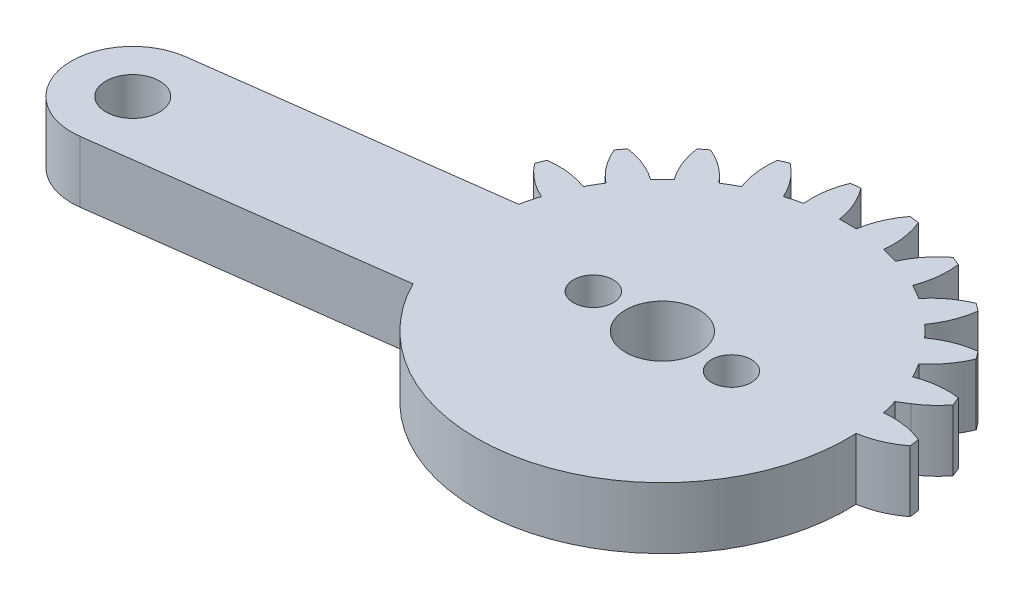
from build123d import *

# Parameters (mm, degrees)
SKETCH1_R           = 1.5
BOSS_EXTRUDE1_DEPTH = 4
SKETCH3_R           = 1.75
BOSS_EXTRUDE2_DEPTH = 4
CUT_EXTRUDE1_DEPTH  = 4
CUT_EXTRUDE2_REACH  = 6
SKETCH5_R           = 1.3
SKETCH5_R_2         = 2.4


with BuildPart() as part:
    # Sketch1 → Boss-Extrude1 (new body)
    with BuildSketch(Plane(origin=(0, 0, 0), x_dir=(1, 0, 0), z_dir=(0, 1, 0))):
        with BuildLine():
            Line((20.643657446, 4), (2.081641936, 4))
            ThreePointArc((2.081641936, 4), (2.861028333, 4.588201733), (3.521749436, 5.30713988))
            ThreePointArc((3.521749436, 5.30713988), (3.405395609, 5.596745198), (3.282888305, 5.883801663))
            ThreePointArc((3.282888305, 5.883801663), (1.93527598, 5.894040025), (0.627094961, 5.57027124))
            ThreePointArc((0.627094961, 5.57027124), (0.366286148, 6.046375), (0.084372603, 6.510293938))
            ThreePointArc((0.084372603, 6.510293938), (1.018855105, 7.48132754), (1.683794586, 8.65351323))
            ThreePointArc((1.683794586, 8.65351323), (1.496450048, 8.903135899), (1.303821399, 9.148703928))
            ThreePointArc((1.303821399, 9.148703928), (-0.000522033, 8.809805691), (-1.180330337, 8.158486898))
            ThreePointArc((-1.180330337, 8.158486898), (-1.555477026, 8.550865528), (-1.947855656, 8.926012217))
            ThreePointArc((-1.947855656, 8.926012217), (-1.296536862, 10.105820521), (-0.957638625, 11.410163953))
            ThreePointArc((-0.957638625, 11.410163953), (-1.203206655, 11.602792602), (-1.452829324, 11.79013714))
            ThreePointArc((-1.452829324, 11.79013714), (-2.625015014, 11.125197659), (-3.596048616, 10.190715157))
            ThreePointArc((-3.596048616, 10.190715157), (-4.059967554, 10.472628702), (-4.536071314, 10.733437515))
            ThreePointArc((-4.536071314, 10.733437515), (-4.212302529, 12.041618533), (-4.222540891, 13.389230859))
            ThreePointArc((-4.222540891, 13.389230859), (-4.509597355, 13.511738163), (-4.799202674, 13.62809199))
            ThreePointArc((-4.799202674, 13.62809199), (-5.759348103, 12.682425791), (-6.455432668, 11.528463019))
            ThreePointArc((-6.455432668, 11.528463019), (-6.976508546, 11.680699536), (-7.503891752, 11.809396783))
            ThreePointArc((-7.503891752, 11.809396783), (-7.529737283, 13.156800143), (-7.888414517, 14.455843809))
            ThreePointArc((-7.888414517, 14.455843809), (-8.197396993, 14.499881098), (-8.507248835, 14.537314892))
            ThreePointArc((-8.507248835, 14.537314892), (-9.18992168, 13.375367565), (-9.563620196, 12.080565177))
            ThreePointArc((-9.563620196, 12.080565177), (-10.106342554, 12.09275), (-10.649064912, 12.080565177))
            ThreePointArc((-10.649064912, 12.080565177), (-11.022763428, 13.375367565), (-11.705436272, 14.537314892))
            ThreePointArc((-11.705436272, 14.537314892), (-12.015288115, 14.499881098), (-12.324270591, 14.455843809))
            ThreePointArc((-12.324270591, 14.455843809), (-12.682947825, 13.156800143), (-12.708793355, 11.809396783))
            ThreePointArc((-12.708793355, 11.809396783), (-13.236176561, 11.680699536), (-13.757252439, 11.528463019))
            ThreePointArc((-13.757252439, 11.528463019), (-14.453337005, 12.682425791), (-15.413482434, 13.62809199))
            ThreePointArc((-15.413482434, 13.62809199), (-15.703087752, 13.511738163), (-15.990144217, 13.389230859))
            ThreePointArc((-15.990144217, 13.389230859), (-16.000382579, 12.041618533), (-15.676613793, 10.733437515))
            ThreePointArc((-15.676613793, 10.733437515), (-16.152717554, 10.472628702), (-16.616636492, 10.190715157))
            ThreePointArc((-16.616636492, 10.190715157), (-17.587670094, 11.125197659), (-18.759855783, 11.79013714))
            ThreePointArc((-18.759855783, 11.79013714), (-19.009478453, 11.602792602), (-19.255046482, 11.410163953))
            ThreePointArc((-19.255046482, 11.410163953), (-18.916148245, 10.105820521), (-18.264829452, 8.926012217))
            ThreePointArc((-18.264829452, 8.926012217), (-18.657208082, 8.550865528), (-19.032354771, 8.158486898))
            ThreePointArc((-19.032354771, 8.158486898), (-20.212163074, 8.809805691), (-21.516506507, 9.148703928))
            ThreePointArc((-21.516506507, 9.148703928), (-21.709135156, 8.903135899), (-21.896479694, 8.65351323))
            ThreePointArc((-21.896479694, 8.65351323), (-21.231540213, 7.48132754), (-20.297057711, 6.510293938))
            ThreePointArc((-20.297057711, 6.510293938), (-20.578971255, 6.046375), (-20.839780068, 5.57027124))
            ThreePointArc((-20.839780068, 5.57027124), (-22.147961087, 5.894040025), (-23.495573413, 5.883801663))
            ThreePointArc((-23.495573413, 5.883801663), (-23.618080717, 5.596745198), (-23.734434544, 5.30713988))
            ThreePointArc((-23.734434544, 5.30713988), (-22.788768345, 4.346994451), (-21.634805572, 3.650909885))
            ThreePointArc((-21.634805572, 3.650909885), (-21.78704209, 3.129834008), (-21.915739337, 2.602450802))
            ThreePointArc((-21.915739337, 2.602450802), (-23.263142697, 2.576605271), (-24.562186363, 2.217928037))
            ThreePointArc((-24.562186363, 2.217928037), (-24.606223651, 1.908945561), (-24.643657446, 1.599093719))
            ThreePointArc((-24.643657446, 1.599093719), (-23.481710119, 0.916420874), (-22.186907731, 0.542722358))
            ThreePointArc((-22.186907731, 0.542722358), (-22.199092554, 0), (-22.186907731, -0.542722358))
            ThreePointArc((-22.186907731, -0.542722358), (-23.481710119, -0.916420874), (-24.643657446, -1.599093719))
            ThreePointArc((-24.643657446, -1.599093719), (-24.606223651, -1.908945561), (-24.562186363, -2.217928037))
            ThreePointArc((-24.562186363, -2.217928037), (-23.263142697, -2.576605271), (-21.915739337, -2.602450802))
            ThreePointArc((-21.915739337, -2.602450802), (-21.78704209, -3.129834008), (-21.634805572, -3.650909885))
            ThreePointArc((-21.634805572, -3.650909885), (-22.788768345, -4.346994451), (-23.734434544, -5.30713988))
            ThreePointArc((-23.734434544, -5.30713988), (-23.618080717, -5.596745198), (-23.495573413, -5.883801663))
            ThreePointArc((-23.495573413, -5.883801663), (-22.147961087, -5.894040025), (-20.839780068, -5.57027124))
            ThreePointArc((-20.839780068, -5.57027124), (-20.578971255, -6.046375), (-20.297057711, -6.510293938))
            ThreePointArc((-20.297057711, -6.510293938), (-21.231540213, -7.48132754), (-21.896479694, -8.65351323))
            ThreePointArc((-21.896479694, -8.65351323), (-21.709135156, -8.903135899), (-21.516506507, -9.148703928))
            ThreePointArc((-21.516506507, -9.148703928), (-20.212163074, -8.809805691), (-19.032354771, -8.158486898))
            ThreePointArc((-19.032354771, -8.158486898), (-18.657208082, -8.550865528), (-18.264829452, -8.926012217))
            ThreePointArc((-18.264829452, -8.926012217), (-18.916148245, -10.105820521), (-19.255046482, -11.410163953))
            ThreePointArc((-19.255046482, -11.410163953), (-19.009478453, -11.602792602), (-18.759855783, -11.79013714))
            ThreePointArc((-18.759855783, -11.79013714), (-17.587670094, -11.125197659), (-16.616636492, -10.190715157))
            ThreePointArc((-16.616636492, -10.190715157), (-16.152717554, -10.472628702), (-15.676613793, -10.733437515))
            ThreePointArc((-15.676613793, -10.733437515), (-16.000382579, -12.041618533), (-15.990144217, -13.389230859))
            ThreePointArc((-15.990144217, -13.389230859), (-15.703087752, -13.511738163), (-15.413482434, -13.62809199))
            ThreePointArc((-15.413482434, -13.62809199), (-14.453337005, -12.682425791), (-13.757252439, -11.528463019))
            ThreePointArc((-13.757252439, -11.528463019), (-13.236176561, -11.680699536), (-12.708793355, -11.809396783))
            ThreePointArc((-12.708793355, -11.809396783), (-12.682947825, -13.156800143), (-12.324270591, -14.455843809))
            ThreePointArc((-12.324270591, -14.455843809), (-12.015288115, -14.499881098), (-11.705436272, -14.537314892))
            ThreePointArc((-11.705436272, -14.537314892), (-11.022763428, -13.375367565), (-10.649064912, -12.080565177))
            ThreePointArc((-10.649064912, -12.080565177), (-10.106342554, -12.09275), (-9.563620196, -12.080565177))
            ThreePointArc((-9.563620196, -12.080565177), (-9.18992168, -13.375367565), (-8.507248835, -14.537314892))
            ThreePointArc((-8.507248835, -14.537314892), (-8.197396993, -14.499881098), (-7.888414517, -14.455843809))
            ThreePointArc((-7.888414517, -14.455843809), (-7.529737283, -13.156800143), (-7.503891752, -11.809396783))
            ThreePointArc((-7.503891752, -11.809396783), (-6.976508546, -11.680699536), (-6.455432668, -11.528463019))
            ThreePointArc((-6.455432668, -11.528463019), (-5.759348103, -12.682425791), (-4.799202674, -13.62809199))
            ThreePointArc((-4.799202674, -13.62809199), (-4.509597355, -13.511738163), (-4.222540891, -13.389230859))
            ThreePointArc((-4.222540891, -13.389230859), (-4.212302529, -12.041618533), (-4.536071314, -10.733437515))
            ThreePointArc((-4.536071314, -10.733437515), (-4.059967554, -10.472628702), (-3.596048616, -10.190715157))
            ThreePointArc((-3.596048616, -10.190715157), (-2.625015014, -11.125197659), (-1.452829324, -11.79013714))
            ThreePointArc((-1.452829324, -11.79013714), (-1.203206655, -11.602792602), (-0.957638625, -11.410163953))
            ThreePointArc((-0.957638625, -11.410163953), (-1.296536862, -10.105820521), (-1.947855656, -8.926012217))
            ThreePointArc((-1.947855656, -8.926012217), (-1.555477026, -8.550865528), (-1.180330337, -8.158486898))
            ThreePointArc((-1.180330337, -8.158486898), (-0.000522033, -8.809805691), (1.303821399, -9.148703928))
            ThreePointArc((1.303821399, -9.148703928), (1.496450048, -8.903135899), (1.683794586, -8.65351323))
            ThreePointArc((1.683794586, -8.65351323), (1.018855105, -7.48132754), (0.084372603, -6.510293938))
            ThreePointArc((0.084372603, -6.510293938), (0.366286148, -6.046375), (0.627094961, -5.57027124))
            ThreePointArc((0.627094961, -5.57027124), (1.93527598, -5.894040025), (3.282888305, -5.883801663))
            ThreePointArc((3.282888305, -5.883801663), (3.405395609, -5.596745198), (3.521749436, -5.30713988))
            ThreePointArc((3.521749436, -5.30713988), (2.861028333, -4.588201733), (2.081641936, -4))
            Line((2.081641936, -4), (20.643657446, -4))
            ThreePointArc((20.643657446, -4), (24.643657446, 0), (20.643657446, 4))
        make_face()
        with Locations((-10.106342554, 0)):
            Circle(SKETCH1_R, mode=Mode.SUBTRACT)
        with Locations((20.643657446, 0)):
            Circle(SKETCH1_R, mode=Mode.SUBTRACT)
    extrude(amount=BOSS_EXTRUDE1_DEPTH)

    # Sketch3 → Boss-Extrude2 (add)
    with BuildSketch(Plane(origin=(0, 4, 0), x_dir=(1, 0, 0), z_dir=(0, 1, 0))):
        with BuildLine():
            ThreePointArc((-9.584237785, -3.965779445), (-14.072121999, -0.522104769), (-10.628447323, 3.965779445))
            Line((-10.628447323, 3.965779445), (-41.11537681, -0.047900965))
            ThreePointArc((-41.11537681, -0.047900965), (-44.559051487, -4.53578518), (-40.071167272, -7.979459856))
            Line((-40.071167272, -7.979459856), (-9.584237785, -3.965779445))
        make_face()
        with Locations((-40.593272041, -4.013680411)):
            Circle(SKETCH3_R, mode=Mode.SUBTRACT)
    extrude(amount=-BOSS_EXTRUDE2_DEPTH)

    # Sketch4 → Cut-Extrude1 (cut)
    with BuildSketch(Plane(origin=(0, 4, 0), x_dir=(1, 0, 0), z_dir=(0, 1, 0))):
        with BuildLine():
            ThreePointArc((20.643657446, -4), (24.643657446, 0), (20.643657446, 4))
            Line((20.643657446, 4), (2.081641936, 4))
            Line((2.081641936, 4), (1.43808022, 3.600125745))
            ThreePointArc((1.43808022, 3.600125745), (1.581217534, 3.104116905), (1.70305423, 2.602450802))
            ThreePointArc((1.70305423, 2.602450802), (3.050457589, 2.576605271), (4.349501255, 2.217928037))
            ThreePointArc((4.349501255, 2.217928037), (4.393538544, 1.908945561), (4.430972339, 1.599093719))
            ThreePointArc((4.430972339, 1.599093719), (3.269025011, 0.916420874), (1.974222624, 0.542722358))
            ThreePointArc((1.974222624, 0.542722358), (1.70305423, -2.602450802), (0.627094961, -5.57027124))
            ThreePointArc((0.627094961, -5.57027124), (1.93527598, -5.894040025), (3.282888305, -5.883801663))
            ThreePointArc((3.282888305, -5.883801663), (3.405395609, -5.596745198), (3.521749436, -5.30713988))
            ThreePointArc((3.521749436, -5.30713988), (2.861028333, -4.588201733), (2.081641936, -4))
            Line((2.081641936, -4), (20.643657446, -4))
        make_face()
        with BuildLine():
            ThreePointArc((1.683794586, -8.65351323), (1.018855105, -7.48132754), (0.084372603, -6.510293938))
            ThreePointArc((0.084372603, -6.510293938), (-0.512518948, -7.361599771), (-1.180330337, -8.158486898))
            ThreePointArc((-1.180330337, -8.158486898), (-0.000522033, -8.809805691), (1.303821399, -9.148703928))
            ThreePointArc((1.303821399, -9.148703928), (1.496450048, -8.903135899), (1.683794586, -8.65351323))
        make_face()
        with BuildLine():
            ThreePointArc((-0.957638625, -11.410163953), (-1.296536862, -10.105820521), (-1.947855656, -8.926012217))
            ThreePointArc((-1.947855656, -8.926012217), (-2.744742783, -9.593823606), (-3.596048616, -10.190715157))
            ThreePointArc((-3.596048616, -10.190715157), (-2.625015014, -11.125197659), (-1.452829324, -11.79013714))
            ThreePointArc((-1.452829324, -11.79013714), (-1.203206655, -11.602792602), (-0.957638625, -11.410163953))
        make_face()
        with BuildLine():
            ThreePointArc((-4.222540891, -13.389230859), (-4.212302529, -12.041618533), (-4.536071314, -10.733437515))
            ThreePointArc((-4.536071314, -10.733437515), (-5.478647477, -11.172244217), (-6.455432668, -11.528463019))
            ThreePointArc((-6.455432668, -11.528463019), (-5.759348103, -12.682425791), (-4.799202674, -13.62809199))
            ThreePointArc((-4.799202674, -13.62809199), (-4.509597355, -13.511738163), (-4.222540891, -13.389230859))
        make_face()
        with BuildLine():
            ThreePointArc((-7.888414517, -14.455843809), (-7.529737283, -13.156800143), (-7.503891752, -11.809396783))
            ThreePointArc((-7.503891752, -11.809396783), (-8.527921943, -11.989294847), (-9.563620196, -12.080565177))
            ThreePointArc((-9.563620196, -12.080565177), (-9.18992168, -13.375367565), (-8.507248835, -14.537314892))
            ThreePointArc((-8.507248835, -14.537314892), (-8.197396993, -14.499881098), (-7.888414517, -14.455843809))
        make_face()
        with BuildLine():
            ThreePointArc((-11.705436272, -14.537314892), (-11.022763428, -13.375367565), (-10.649064912, -12.080565177))
            ThreePointArc((-10.649064912, -12.080565177), (-11.684763165, -11.989294847), (-12.708793355, -11.809396783))
            ThreePointArc((-12.708793355, -11.809396783), (-12.682947825, -13.156800143), (-12.324270591, -14.455843809))
            ThreePointArc((-12.324270591, -14.455843809), (-12.015288115, -14.499881098), (-11.705436272, -14.537314892))
        make_face()
        with BuildLine():
            ThreePointArc((-15.413482434, -13.62809199), (-14.453337005, -12.682425791), (-13.757252439, -11.528463019))
            ThreePointArc((-13.757252439, -11.528463019), (-14.734037631, -11.172244217), (-15.676613793, -10.733437515))
            ThreePointArc((-15.676613793, -10.733437515), (-16.000382579, -12.041618533), (-15.990144217, -13.389230859))
            ThreePointArc((-15.990144217, -13.389230859), (-15.703087752, -13.511738163), (-15.413482434, -13.62809199))
        make_face()
        with BuildLine():
            ThreePointArc((-18.759855783, -11.79013714), (-17.587670094, -11.125197659), (-16.616636492, -10.190715157))
            ThreePointArc((-16.616636492, -10.190715157), (-17.467942324, -9.593823606), (-18.264829452, -8.926012217))
            ThreePointArc((-18.264829452, -8.926012217), (-18.916148245, -10.105820521), (-19.255046482, -11.410163953))
            ThreePointArc((-19.255046482, -11.410163953), (-19.009478453, -11.602792602), (-18.759855783, -11.79013714))
        make_face()
        with BuildLine():
            ThreePointArc((-21.516506507, -9.148703928), (-20.212163074, -8.809805691), (-19.032354771, -8.158486898))
            ThreePointArc((-19.032354771, -8.158486898), (-19.70016616, -7.361599771), (-20.297057711, -6.510293938))
            ThreePointArc((-20.297057711, -6.510293938), (-21.231540213, -7.48132754), (-21.896479694, -8.65351323))
            ThreePointArc((-21.896479694, -8.65351323), (-21.709135156, -8.903135899), (-21.516506507, -9.148703928))
        make_face()
        with BuildLine():
            ThreePointArc((-21.942853375, 2.47620963), (-21.92946485, 2.539366405), (-21.915739337, 2.602450802))
            ThreePointArc((-21.915739337, 2.602450802), (-23.263142697, 2.576605271), (-24.562186363, 2.217928037))
            ThreePointArc((-24.562186363, 2.217928037), (-24.56889027, 2.173784387), (-24.575459377, 2.129620475))
            Line((-24.575459377, 2.129620475), (-21.942853375, 2.47620963))
        make_face()
        with BuildLine():
            ThreePointArc((-23.495573413, -5.883801663), (-22.147961087, -5.894040025), (-20.839780068, -5.57027124))
            ThreePointArc((-20.839780068, -5.57027124), (-20.869365339, -5.512888815), (-20.898643838, -5.455349261))
            Line((-20.898643838, -5.455349261), (-23.531249839, -5.801938416))
            ThreePointArc((-23.531249839, -5.801938416), (-23.513474108, -5.842897269), (-23.495573413, -5.883801663))
        make_face()
    extrude(amount=-CUT_EXTRUDE1_DEPTH, mode=Mode.SUBTRACT)

    # Sketch5 → Cut-Extrude2 (cut, up to next)
    with BuildSketch(Plane(origin=(0, 4, 0), x_dir=(1, 0, 0), z_dir=(0, 1, 0)), mode=Mode.PRIVATE) as cut_extrude2_sk1:
        with Locations((-14.606342554, 0)):
            Circle(SKETCH5_R)
    cut_extrude2_tool1 = extrude(cut_extrude2_sk1.sketch, amount=-CUT_EXTRUDE2_REACH, mode=Mode.PRIVATE) & part.part
    add(cut_extrude2_tool1.solids().sort_by_distance((-14.606343, 4, 0))[0], mode=Mode.SUBTRACT)
    # Sketch5 → Cut-Extrude2 (cut, up to next)
    with BuildSketch(Plane(origin=(0, 4, 0), x_dir=(1, 0, 0), z_dir=(0, 1, 0)), mode=Mode.PRIVATE) as cut_extrude2_sk2:
        with Locations((-5.606342554, 0)):
            Circle(SKETCH5_R)
    cut_extrude2_tool2 = extrude(cut_extrude2_sk2.sketch, amount=-CUT_EXTRUDE2_REACH, mode=Mode.PRIVATE) & part.part
    add(cut_extrude2_tool2.solids().sort_by_distance((-5.606343, 4, 0))[0], mode=Mode.SUBTRACT)
    # Sketch5 → Cut-Extrude2 (cut, up to next)
    with BuildSketch(Plane(origin=(0, 4, 0), x_dir=(1, 0, 0), z_dir=(0, 1, 0)), mode=Mode.PRIVATE) as cut_extrude2_sk3:
        with Locations((-10.106342554, 0)):
            Circle(SKETCH5_R_2)
    cut_extrude2_tool3 = extrude(cut_extrude2_sk3.sketch, amount=-CUT_EXTRUDE2_REACH, mode=Mode.PRIVATE) & part.part
    add(cut_extrude2_tool3.solids().sort_by_distance((-10.106343, 4, 0))[0], mode=Mode.SUBTRACT)


solid = part.part
